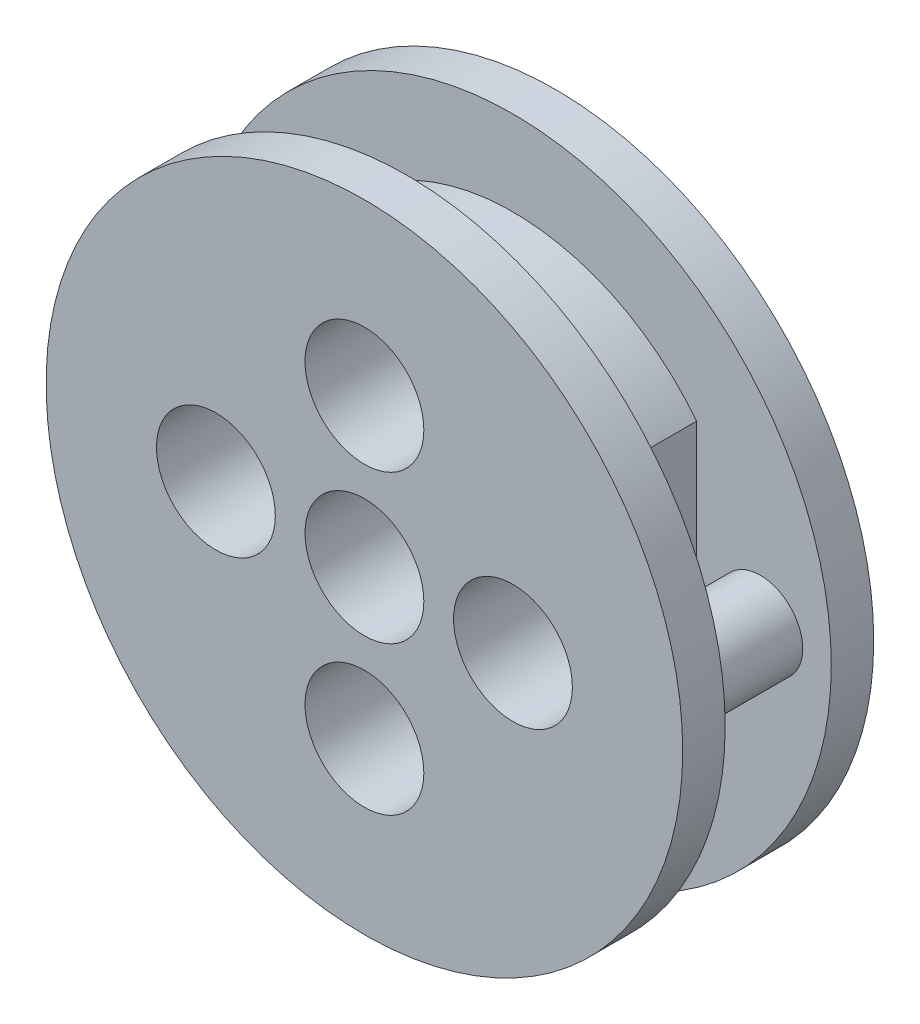
from build123d import *

# Parameters (mm, degrees)
SKETCH_1_R          = 15
EXTRUDE_1_DEPTH     = 2
SKETCH_2_R          = 2
EXTRUDE_2_DEPTH     = 5
SKETCH_3_R          = 15
EXTRUDE_3_DEPTH     = 2
CUT_EXTRUDE_1_REACH = 11
SKETCH_4_R          = 1.5
SKETCH_4_R_2        = 2.8
SKETCH_5_R          = 2.8
CUT_EXTRUDE_2_DEPTH = 5


with BuildPart() as part:
    # 草图1 → 凸台-拉伸1 (new body)
    with BuildSketch(Plane.XY):
        Circle(SKETCH_1_R)
    extrude(amount=EXTRUDE_1_DEPTH)

    # 草图2 → 凸台-拉伸2 (add)
    with BuildSketch(Plane.XY.offset(2)):
        with Locations((11.655867717, 0)):
            Circle(SKETCH_2_R)
        with BuildLine():
            Line((8.655867717, 6.787927082), (8.655867717, -6.787927082))
            ThreePointArc((8.655867717, -6.787927082), (-11, 0), (8.655867717, 6.787927082))
        make_face()
    extrude(amount=EXTRUDE_2_DEPTH)

    # 草图3 → 凸台-拉伸3 (add)
    with BuildSketch(Plane.XY.offset(7)):
        Circle(SKETCH_3_R)
    extrude(amount=EXTRUDE_3_DEPTH)

    # 草图4 → 切除-拉伸1 (cut, up to next)
    with BuildSketch(Plane(origin=(0, 0, 0), x_dir=(-1, 0, 0), z_dir=(0, 0, -1)), mode=Mode.PRIVATE) as cut_extrude_1_sk1:
        with Locations((0, 7)):
            Circle(SKETCH_4_R)
    cut_extrude_1_tool1 = extrude(cut_extrude_1_sk1.sketch, amount=-CUT_EXTRUDE_1_REACH, mode=Mode.PRIVATE) & part.part
    add(cut_extrude_1_tool1.solids().sort_by_distance((0, 7, 0))[0], mode=Mode.SUBTRACT)
    # 草图4 → 切除-拉伸1 (cut, up to next)
    with BuildSketch(Plane(origin=(0, 0, 0), x_dir=(-1, 0, 0), z_dir=(0, 0, -1)), mode=Mode.PRIVATE) as cut_extrude_1_sk2:
        with Locations((0, -7)):
            Circle(SKETCH_4_R)
    cut_extrude_1_tool2 = extrude(cut_extrude_1_sk2.sketch, amount=-CUT_EXTRUDE_1_REACH, mode=Mode.PRIVATE) & part.part
    add(cut_extrude_1_tool2.solids().sort_by_distance((0, -7, 0))[0], mode=Mode.SUBTRACT)
    # 草图4 → 切除-拉伸1 (cut, up to next)
    with BuildSketch(Plane(origin=(0, 0, 0), x_dir=(-1, 0, 0), z_dir=(0, 0, -1)), mode=Mode.PRIVATE) as cut_extrude_1_sk3:
        with Locations((7, 0)):
            Circle(SKETCH_4_R)
    cut_extrude_1_tool3 = extrude(cut_extrude_1_sk3.sketch, amount=-CUT_EXTRUDE_1_REACH, mode=Mode.PRIVATE) & part.part
    add(cut_extrude_1_tool3.solids().sort_by_distance((-7, 0, 0))[0], mode=Mode.SUBTRACT)
    # 草图4 → 切除-拉伸1 (cut, up to next)
    with BuildSketch(Plane(origin=(0, 0, 0), x_dir=(-1, 0, 0), z_dir=(0, 0, -1)), mode=Mode.PRIVATE) as cut_extrude_1_sk4:
        with Locations((-7, 0)):
            Circle(SKETCH_4_R)
    cut_extrude_1_tool4 = extrude(cut_extrude_1_sk4.sketch, amount=-CUT_EXTRUDE_1_REACH, mode=Mode.PRIVATE) & part.part
    add(cut_extrude_1_tool4.solids().sort_by_distance((7, 0, 0))[0], mode=Mode.SUBTRACT)
    # 草图4 → 切除-拉伸1 (cut, up to next)
    with BuildSketch(Plane(origin=(0, 0, 0), x_dir=(-1, 0, 0), z_dir=(0, 0, -1)), mode=Mode.PRIVATE) as cut_extrude_1_sk5:
        Circle(SKETCH_4_R_2)
    cut_extrude_1_tool5 = extrude(cut_extrude_1_sk5.sketch, amount=-CUT_EXTRUDE_1_REACH, mode=Mode.PRIVATE) & part.part
    add(cut_extrude_1_tool5.solids().sort_by_distance((0, 0, 0))[0], mode=Mode.SUBTRACT)

    # 草图5 → 切除-拉伸2 (cut)
    with BuildSketch(Plane.XY.offset(9)):
        with Locations((0, 7)):
            Circle(SKETCH_5_R)
        with Locations((7, 0)):
            Circle(SKETCH_5_R)
        with Locations((-7, 0)):
            Circle(SKETCH_5_R)
        with Locations((0, -7)):
            Circle(SKETCH_5_R)
    extrude(amount=-CUT_EXTRUDE_2_DEPTH, mode=Mode.SUBTRACT)


solid = part.part
